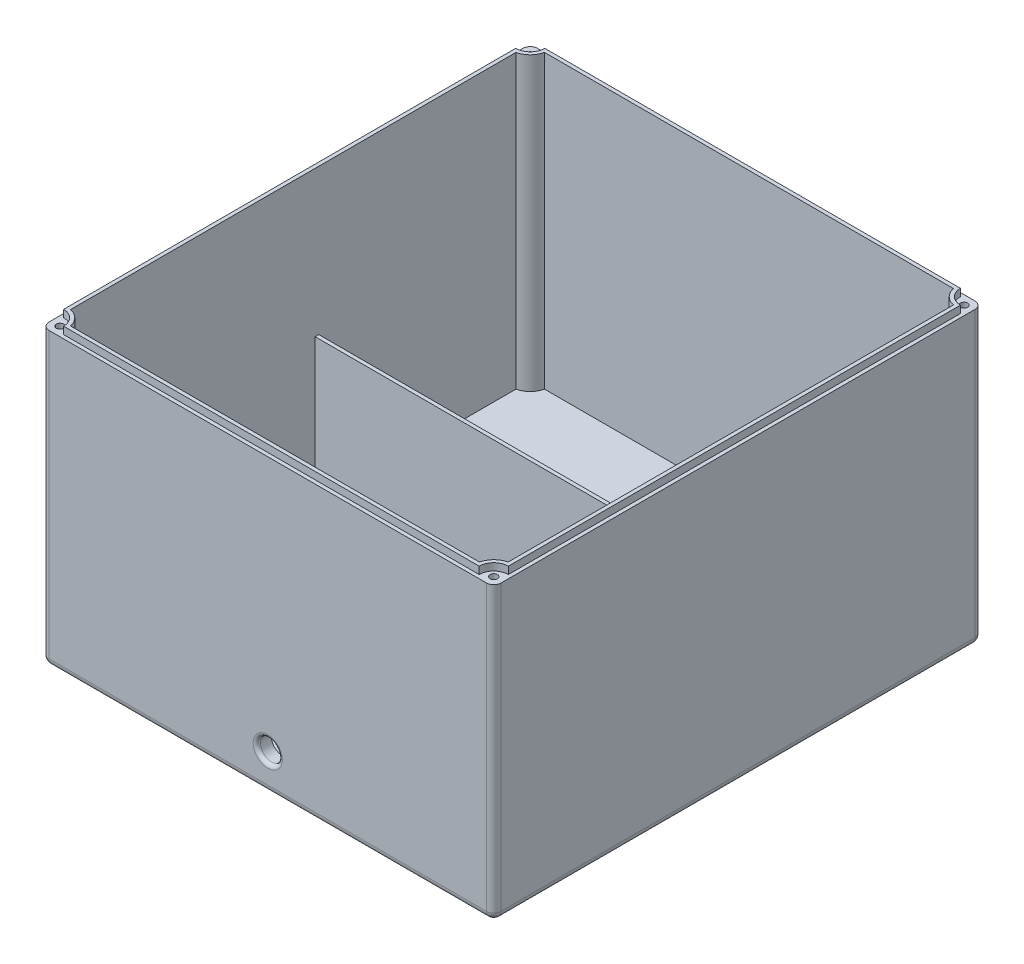
from build123d import *

# Parameters (mm, degrees)
SKETCH1_W                 = 124
SKETCH1_H                 = 134
BOSS_EXTRUDE1_DEPTH       = 80
BOSS_EXTRUDE2_DEPTH       = 2
CUT_EXTRUDE3_DEPTH        = 80
FILLET1_R                 = 2
SKETCH5_R                 = 4
BOSS_EXTRUDE4_DEPTH       = 4
SKETCH9_R                 = 4
BOSS_EXTRUDE5_DEPTH       = 4
SKETCH10_R                = 3
CUT_EXTRUDE5_DEPTH        = 1
CUT_EXTRUDE5_DEPTH_BACK   = 135
FILLET3_R                 = 1
F_2_0MM_DOWEL_HOLE1_D     = 2
F_2_0MM_DOWEL_HOLE1_DEPTH = 20
F_2_0MM_DOWEL_HOLE1_TIP   = 0.600860619
SKETCH14_W                = 120
SKETCH14_H                = 1
BOSS_EXTRUDE6_DEPTH       = 40


with BuildPart() as part:
    # Sketch1 → Boss-Extrude1 (new body)
    with BuildSketch(Plane(origin=(0, 0, 0), x_dir=(1, 0, 0), z_dir=(0, 1, 0))):
        Rectangle(SKETCH1_W, SKETCH1_H)
    extrude(amount=BOSS_EXTRUDE1_DEPTH)

    # Sketch2 → Boss-Extrude2 (add)
    with BuildSketch(Plane(origin=(0, 80, 0), x_dir=(1, 0, 0), z_dir=(0, 1, 0))):
        with BuildLine():
            Line((57, 66), (-57, 66))
            ThreePointArc((-57, 66), (-58.171572875, 63.171572875), (-61, 62))
            Line((-61, 62), (-61, -62))
            ThreePointArc((-61, -62), (-58.171572875, -63.171572875), (-57, -66))
            Line((-57, -66), (57, -66))
            ThreePointArc((57, -66), (58.171572875, -63.171572875), (61, -62))
            Line((61, -62), (61, 62))
            ThreePointArc((61, 62), (58.171572875, 63.171572875), (57, 66))
        make_face()
    extrude(amount=BOSS_EXTRUDE2_DEPTH)

    # Sketch3 → Cut-Extrude3 (cut)
    with BuildSketch(Plane(origin=(0, 82, 0), x_dir=(1, 0, 0), z_dir=(0, 1, 0))):
        with BuildLine():
            Line((56.101020514, 65), (-56.101020514, 65))
            ThreePointArc((-56.101020514, 65), (-57.464466094, 62.464466094), (-60, 61.101020514))
            Line((-60, 61.101020514), (-60, -61.101020514))
            ThreePointArc((-60, -61.101020514), (-57.464466094, -62.464466094), (-56.101020514, -65))
            Line((-56.101020514, -65), (56.101020514, -65))
            ThreePointArc((56.101020514, -65), (57.464466094, -62.464466094), (60, -61.101020514))
            Line((60, -61.101020514), (60, 61.101020514))
            ThreePointArc((60, 61.101020514), (57.464466094, 62.464466094), (56.101020514, 65))
        make_face()
    extrude(amount=-CUT_EXTRUDE3_DEPTH, mode=Mode.SUBTRACT)

    # Fillet1
    fillet1_edges = [part.edges().sort_by_distance(p)[0] for p in [
        (0, 0, -67),
        (62, 0, 0),
        (0, 0, 67),
        (-62, 0, 0),
        (-62, 40, -67),
        (62, 40, -67),
        (62, 40, 67),
        (-62, 40, 67),
    ]]
    fillet(fillet1_edges, radius=FILLET1_R)

    # Sketch5 → Boss-Extrude4 (add)
    with BuildSketch(Plane.XY.offset(67)):
        with Locations((0, 10)):
            Circle(SKETCH5_R)
    extrude(amount=-BOSS_EXTRUDE4_DEPTH)

    # Sketch9 → Boss-Extrude5 (add)
    with BuildSketch(Plane(origin=(0, 0, -67), x_dir=(-1, 0, 0), z_dir=(0, 0, -1))):
        with Locations((0, 10)):
            Circle(SKETCH9_R)
    extrude(amount=-BOSS_EXTRUDE5_DEPTH)

    # Sketch10 → Cut-Extrude5 (cut, two sides)
    with BuildSketch(Plane(origin=(0, 0, -67), x_dir=(-1, 0, 0), z_dir=(0, 0, -1))) as cut_extrude5_sk:
        with Locations((0, 10)):
            Circle(SKETCH10_R)
    extrude(amount=CUT_EXTRUDE5_DEPTH, mode=Mode.SUBTRACT)
    extrude(cut_extrude5_sk.sketch, amount=-CUT_EXTRUDE5_DEPTH_BACK, mode=Mode.SUBTRACT)

    # Fillet3
    fillet3_edges = [part.edges().sort_by_distance(p)[0] for p in [
        (3, 10, -67),
        (3, 10, 67),
    ]]
    fillet(fillet3_edges, radius=FILLET3_R)

    # Ø2.0mm Dowel Hole1
    with Locations(Plane(origin=(59.5, 80, -64.5), x_dir=(0, 0, 1), z_dir=(0, 1, 0))):
        with Locations((0, 0), (129, 0), (129, -119), (0, -119)):
            Hole(F_2_0MM_DOWEL_HOLE1_D / 2, depth=F_2_0MM_DOWEL_HOLE1_DEPTH)
            with Locations((0, 0, -(F_2_0MM_DOWEL_HOLE1_DEPTH + F_2_0MM_DOWEL_HOLE1_TIP / 2))):  # 118° drill point
                Cone(0, F_2_0MM_DOWEL_HOLE1_D / 2, F_2_0MM_DOWEL_HOLE1_TIP, mode=Mode.SUBTRACT)

    # Sketch14 → Boss-Extrude6 (add)
    with BuildSketch(Plane(origin=(0, 2, 0), x_dir=(1, 0, 0), z_dir=(0, 1, 0))):
        with Locations((0, 6.5)):
            Rectangle(SKETCH14_W, SKETCH14_H)
    extrude(amount=BOSS_EXTRUDE6_DEPTH)


solid = part.part
